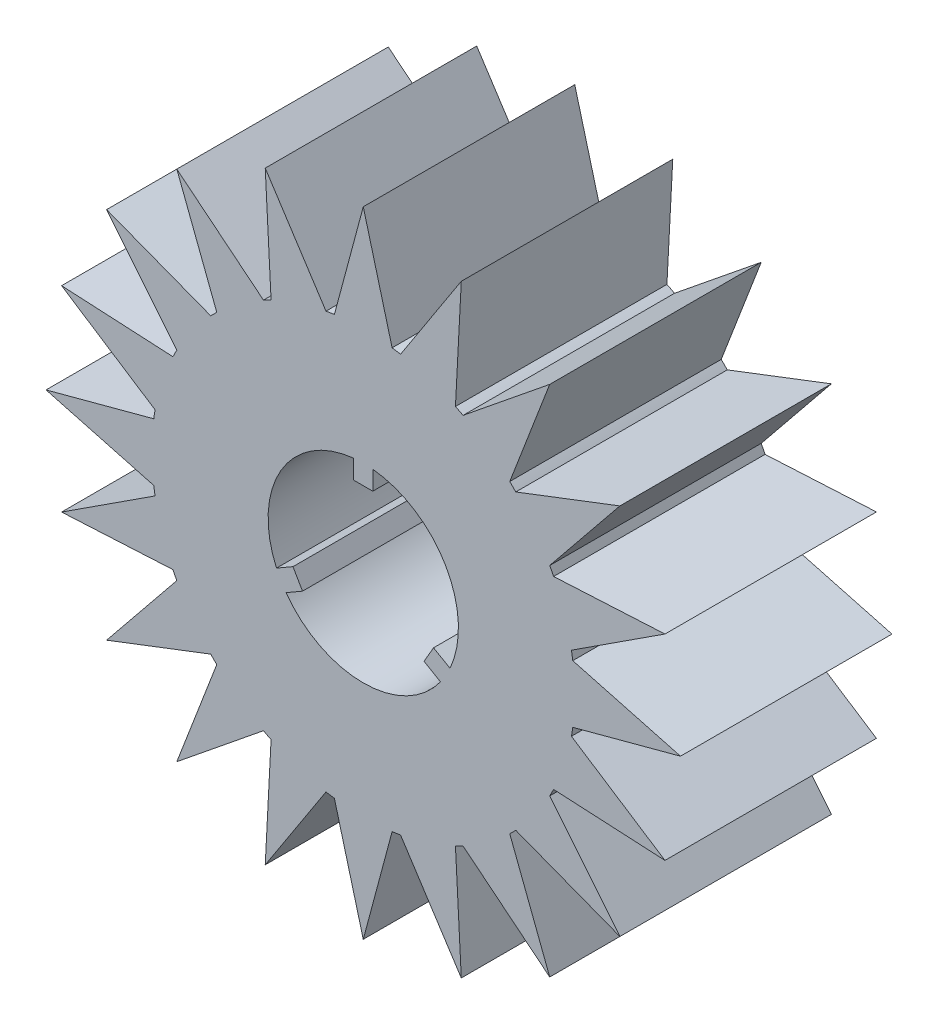
from build123d import *

# Parameters (mm, degrees)
BOSS_EXTRUDE1_DEPTH = 10


with BuildPart() as part:
    # Sketch1 → Boss-Extrude1 (new body)
    with BuildSketch(Plane.XY):
        with BuildLine():
            Line((0, 15), (-1.36481914, 9.906425628))
            ThreePointArc((-1.36481914, 9.906425628), (-1.56434465, 9.876883406), (-1.763233736, 9.843322955))
            Line((-1.763233736, 9.843322955), (-4.635254916, 14.265847744))
            Line((-4.635254916, 14.265847744), (-4.359274009, 8.999818338))
            ThreePointArc((-4.359274009, 8.999818338), (-4.539904997, 8.910065242), (-4.718689009, 8.816687249))
            Line((-4.718689009, 8.816687249), (-8.816778784, 12.135254916))
            Line((-8.816778784, 12.135254916), (-6.927012765, 7.212246124))
            ThreePointArc((-6.927012765, 7.212246124), (-7.071067812, 7.071067812), (-7.212246124, 6.927012765))
            Line((-7.212246124, 6.927012765), (-12.135254916, 8.816778784))
            Line((-12.135254916, 8.816778784), (-8.816687249, 4.718689009))
            ThreePointArc((-8.816687249, 4.718689009), (-8.910065242, 4.539904997), (-8.999818338, 4.359274009))
            Line((-8.999818338, 4.359274009), (-14.265847744, 4.635254916))
            Line((-14.265847744, 4.635254916), (-9.843322955, 1.763233736))
            ThreePointArc((-9.843322955, 1.763233736), (-9.876883406, 1.56434465), (-9.906425628, 1.36481914))
            Line((-9.906425628, 1.36481914), (-15, 0))
            Line((-15, 0), (-9.906425628, -1.36481914))
            ThreePointArc((-9.906425628, -1.36481914), (-9.876883406, -1.56434465), (-9.843322955, -1.763233736))
            Line((-9.843322955, -1.763233736), (-14.265847744, -4.635254916))
            Line((-14.265847744, -4.635254916), (-8.999818338, -4.359274009))
            ThreePointArc((-8.999818338, -4.359274009), (-8.910065242, -4.539904997), (-8.816687249, -4.718689009))
            Line((-8.816687249, -4.718689009), (-12.135254916, -8.816778784))
            Line((-12.135254916, -8.816778784), (-7.212246124, -6.927012765))
            ThreePointArc((-7.212246124, -6.927012765), (-7.071067812, -7.071067812), (-6.927012765, -7.212246124))
            Line((-6.927012765, -7.212246124), (-8.816778784, -12.135254916))
            Line((-8.816778784, -12.135254916), (-4.718689009, -8.816687249))
            ThreePointArc((-4.718689009, -8.816687249), (-4.539904997, -8.910065242), (-4.359274009, -8.999818338))
            Line((-4.359274009, -8.999818338), (-4.635254916, -14.265847744))
            Line((-4.635254916, -14.265847744), (-1.763233736, -9.843322955))
            ThreePointArc((-1.763233736, -9.843322955), (-1.56434465, -9.876883406), (-1.36481914, -9.906425628))
            Line((-1.36481914, -9.906425628), (0, -15))
            Line((0, -15), (1.36481914, -9.906425628))
            ThreePointArc((1.36481914, -9.906425628), (1.56434465, -9.876883406), (1.763233736, -9.843322955))
            Line((1.763233736, -9.843322955), (4.635254916, -14.265847744))
            Line((4.635254916, -14.265847744), (4.359274009, -8.999818338))
            ThreePointArc((4.359274009, -8.999818338), (4.539904997, -8.910065242), (4.718689009, -8.816687249))
            Line((4.718689009, -8.816687249), (8.816778784, -12.135254916))
            Line((8.816778784, -12.135254916), (6.927012765, -7.212246124))
            ThreePointArc((6.927012765, -7.212246124), (7.071067812, -7.071067812), (7.212246124, -6.927012765))
            Line((7.212246124, -6.927012765), (12.135254916, -8.816778784))
            Line((12.135254916, -8.816778784), (8.816687249, -4.718689009))
            ThreePointArc((8.816687249, -4.718689009), (8.910065242, -4.539904997), (8.999818338, -4.359274009))
            Line((8.999818338, -4.359274009), (14.265847744, -4.635254916))
            Line((14.265847744, -4.635254916), (9.843322955, -1.763233736))
            ThreePointArc((9.843322955, -1.763233736), (9.876883406, -1.56434465), (9.906425628, -1.36481914))
            Line((9.906425628, -1.36481914), (15, 0))
            Line((15, 0), (9.906425628, 1.36481914))
            ThreePointArc((9.906425628, 1.36481914), (9.876883406, 1.56434465), (9.843322955, 1.763233736))
            Line((9.843322955, 1.763233736), (14.265847744, 4.635254916))
            Line((14.265847744, 4.635254916), (8.999818338, 4.359274009))
            ThreePointArc((8.999818338, 4.359274009), (8.910065242, 4.539904997), (8.816687249, 4.718689009))
            Line((8.816687249, 4.718689009), (12.135254916, 8.816778784))
            Line((12.135254916, 8.816778784), (7.212246124, 6.927012765))
            ThreePointArc((7.212246124, 6.927012765), (7.071067812, 7.071067812), (6.927012765, 7.212246124))
            Line((6.927012765, 7.212246124), (8.816778784, 12.135254916))
            Line((8.816778784, 12.135254916), (4.718689009, 8.816687249))
            ThreePointArc((4.718689009, 8.816687249), (4.539904997, 8.910065242), (4.359274009, 8.999818338))
            Line((4.359274009, 8.999818338), (4.635254916, 14.265847744))
            Line((4.635254916, 14.265847744), (1.763233736, 9.843322955))
            ThreePointArc((1.763233736, 9.843322955), (1.56434465, 9.876883406), (1.36481914, 9.906425628))
            Line((1.36481914, 9.906425628), (0, 15))
        make_face()
        with BuildLine():
            Line((0.45, 3.577443467), (-0.45, 3.577443467))
            Line((-0.45, 3.577443467), (-0.45, 4.477443467))
            ThreePointArc((-0.45, 4.477443467), (-3.897114317, 2.25), (-4.102579786, -1.849010302))
            Line((-4.102579786, -1.849010302), (-3.323156923, -1.399010302))
            Line((-3.323156923, -1.399010302), (-2.873156923, -2.178433165))
            Line((-2.873156923, -2.178433165), (-3.652579786, -2.628433165))
            ThreePointArc((-3.652579786, -2.628433165), (0, -4.5), (3.652579786, -2.628433165))
            Line((3.652579786, -2.628433165), (2.873156923, -2.178433165))
            Line((2.873156923, -2.178433165), (3.323156923, -1.399010302))
            Line((3.323156923, -1.399010302), (4.102579786, -1.849010302))
            ThreePointArc((4.102579786, -1.849010302), (3.897114317, 2.25), (0.45, 4.477443467))
            Line((0.45, 4.477443467), (0.45, 3.577443467))
        make_face(mode=Mode.SUBTRACT)
    extrude(amount=BOSS_EXTRUDE1_DEPTH)


solid = part.part
